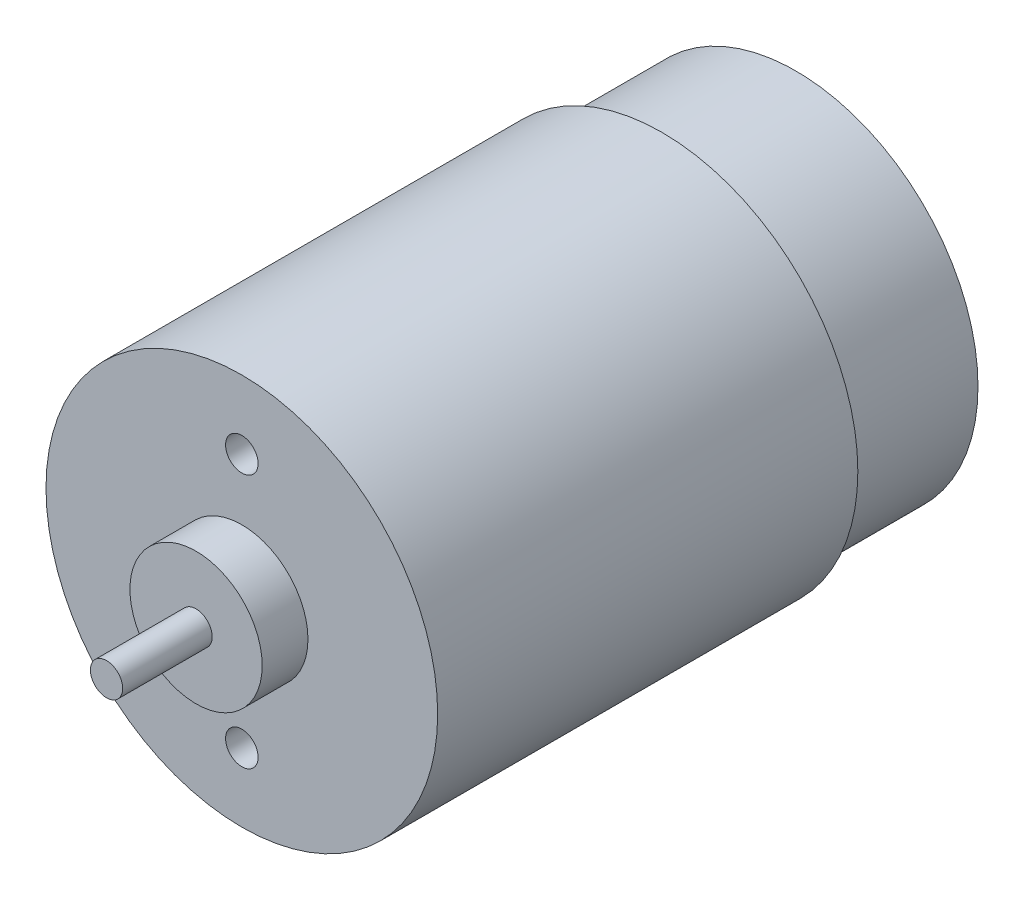
from build123d import *

# Parameters (mm, degrees)
SKETCH1_R           = 19.25
BOSS_EXTRUDE1_DEPTH = 41.3
SKETCH3_R           = 1.585
BOSS_EXTRUDE2_DEPTH = 13.3
SKETCH4_R           = 6.5
BOSS_EXTRUDE3_DEPTH = 4.5
SKETCH5_R           = 17.9
BOSS_EXTRUDE4_DEPTH = 13.16
SKETCH6_R           = 5.1
BOSS_EXTRUDE5_DEPTH = 3
SKETCH7_R           = 2.375
BOSS_EXTRUDE6_DEPTH = 3
SKETCH8_R           = 1.6
CUT_EXTRUDE1_DEPTH  = 2.999994


with BuildPart() as part:
    # Sketch1 → Boss-Extrude1 (new body)
    with BuildSketch(Plane.XY):
        Circle(SKETCH1_R)
    extrude(amount=BOSS_EXTRUDE1_DEPTH)

    # Sketch3 → Boss-Extrude2 (add)
    with BuildSketch(Plane.XY.offset(41.3)):
        Circle(SKETCH3_R)
    extrude(amount=BOSS_EXTRUDE2_DEPTH)

    # Sketch4 → Boss-Extrude3 (add)
    with BuildSketch(Plane.XY.offset(41.3)):
        Circle(SKETCH4_R)
    extrude(amount=BOSS_EXTRUDE3_DEPTH)

    # Sketch5 → Boss-Extrude4 (add)
    with BuildSketch(Plane(origin=(0, 0, 0), x_dir=(-1, 0, 0), z_dir=(0, 0, -1))):
        Circle(SKETCH5_R)
    extrude(amount=BOSS_EXTRUDE4_DEPTH)

    # Sketch6 → Boss-Extrude5 (add)
    with BuildSketch(Plane(origin=(0, 0, -13.16), x_dir=(-1, 0, 0), z_dir=(0, 0, -1))):
        Circle(SKETCH6_R)
    extrude(amount=BOSS_EXTRUDE5_DEPTH)

    # Sketch7 → Boss-Extrude6 (add)
    with BuildSketch(Plane(origin=(0, 0, -16.16), x_dir=(-1, 0, 0), z_dir=(0, 0, -1))):
        Circle(SKETCH7_R)
    extrude(amount=BOSS_EXTRUDE6_DEPTH)

    # Sketch8 → Cut-Extrude1 (cut)
    with BuildSketch(Plane.XY.offset(41.3)):
        with Locations((0, 12.5)):
            Circle(SKETCH8_R)
        with Locations((0, -12.5)):
            Circle(SKETCH8_R)
    extrude(amount=-CUT_EXTRUDE1_DEPTH, mode=Mode.SUBTRACT)


solid = part.part
